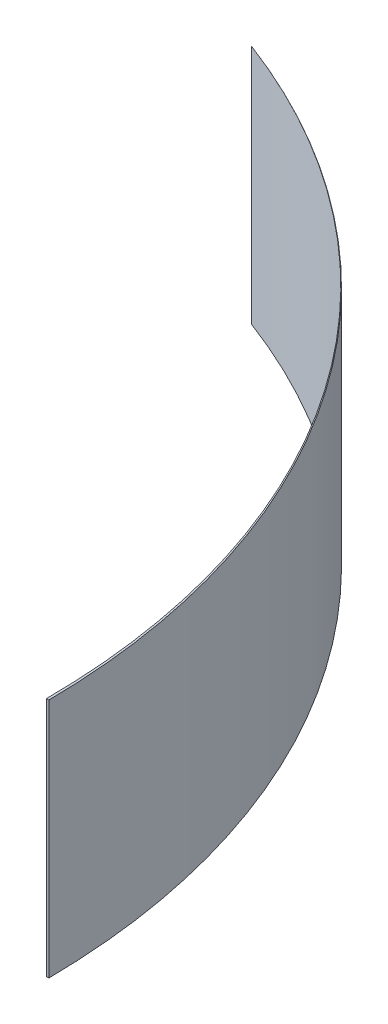
from build123d import *

# Parameters (mm, degrees)
RESSALTO_EXTRUS_O1_DEPTH = 400


with BuildPart() as part:
    # Esboço2 → Ressalto-extrusão1 (new body)
    with BuildSketch(Plane(origin=(0, 0, 0), x_dir=(1, 0, 0), z_dir=(0, 1, 0))):
        with BuildLine():
            ThreePointArc((-768.618984425, 1108.935261213), (-211.954079302, 673.92964707), (0, 0))
            Line((0, 0), (4, 0))
            ThreePointArc((4, 0), (-210.474981394, 674.188420342), (-768.618984425, 1108.935261213))
        make_face()
    extrude(amount=RESSALTO_EXTRUS_O1_DEPTH)


solid = part.part
